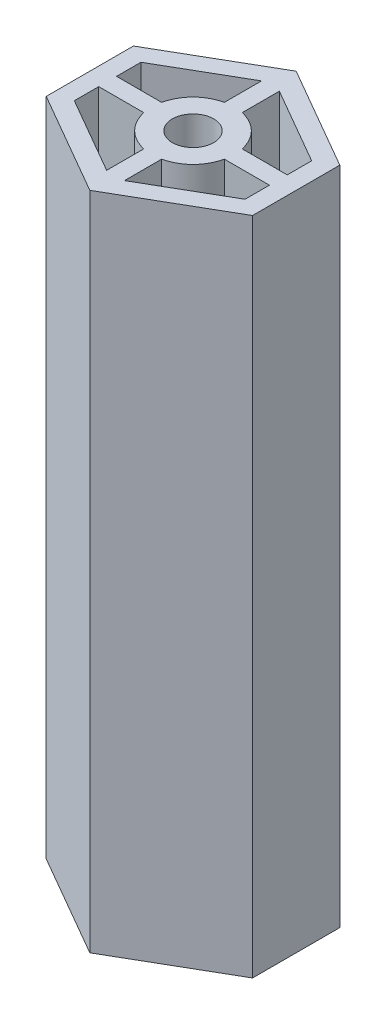
from build123d import *

# Parameters (mm, degrees)
SKETCH1_R           = 2.5
BOSS_EXTRUDE2_DEPTH = 80


with BuildPart() as part:
    # Sketch1 → Boss-Extrude2 (new body)
    with BuildSketch(Plane(origin=(0, 0, 0), x_dir=(1, 0, 0), z_dir=(0, 1, 0))):
        Polygon((-12.5, 5.283121635), (-12.5, -5.283121635), (0, -12.5), (12.5, -5.283121635), (12.5, 5.283121635), (0, 12.5), align=None)
        Circle(SKETCH1_R, mode=Mode.SUBTRACT)
        with BuildLine():
            Line((-1.08, 9.382308546), (-1.08, 4.881966817))
            ThreePointArc((-1.08, 4.881966817), (-3.535533906, 3.535533906), (-4.881966817, 1.08))
            Line((-4.881966817, 1.08), (-10.34, 1.08))
            Line((-10.34, 1.08), (-10.34, 4.036045054))
            Line((-10.34, 4.036045054), (-1.08, 9.382308546))
        make_face(mode=Mode.SUBTRACT)
        with BuildLine():
            Line((1.08, 9.382308546), (1.08, 4.881966817))
            ThreePointArc((1.08, 4.881966817), (3.535533906, 3.535533906), (4.881966817, 1.08))
            Line((4.881966817, 1.08), (10.34, 1.08))
            Line((10.34, 1.08), (10.34, 4.036045054))
            Line((10.34, 4.036045054), (1.08, 9.382308546))
        make_face(mode=Mode.SUBTRACT)
        with BuildLine():
            Line((-10.34, -1.08), (-4.881966817, -1.08))
            ThreePointArc((-4.881966817, -1.08), (-3.535533906, -3.535533906), (-1.08, -4.881966817))
            Line((-1.08, -4.881966817), (-1.08, -9.382308546))
            Line((-1.08, -9.382308546), (-10.34, -4.036045054))
            Line((-10.34, -4.036045054), (-10.34, -1.08))
        make_face(mode=Mode.SUBTRACT)
        with BuildLine():
            Line((1.08, -4.881966817), (1.08, -9.382308546))
            Line((1.08, -9.382308546), (10.34, -4.036045054))
            Line((10.34, -4.036045054), (10.34, -1.08))
            Line((10.34, -1.08), (4.881966817, -1.08))
            ThreePointArc((4.881966817, -1.08), (3.535533906, -3.535533906), (1.08, -4.881966817))
        make_face(mode=Mode.SUBTRACT)
    extrude(amount=BOSS_EXTRUDE2_DEPTH)


solid = part.part
